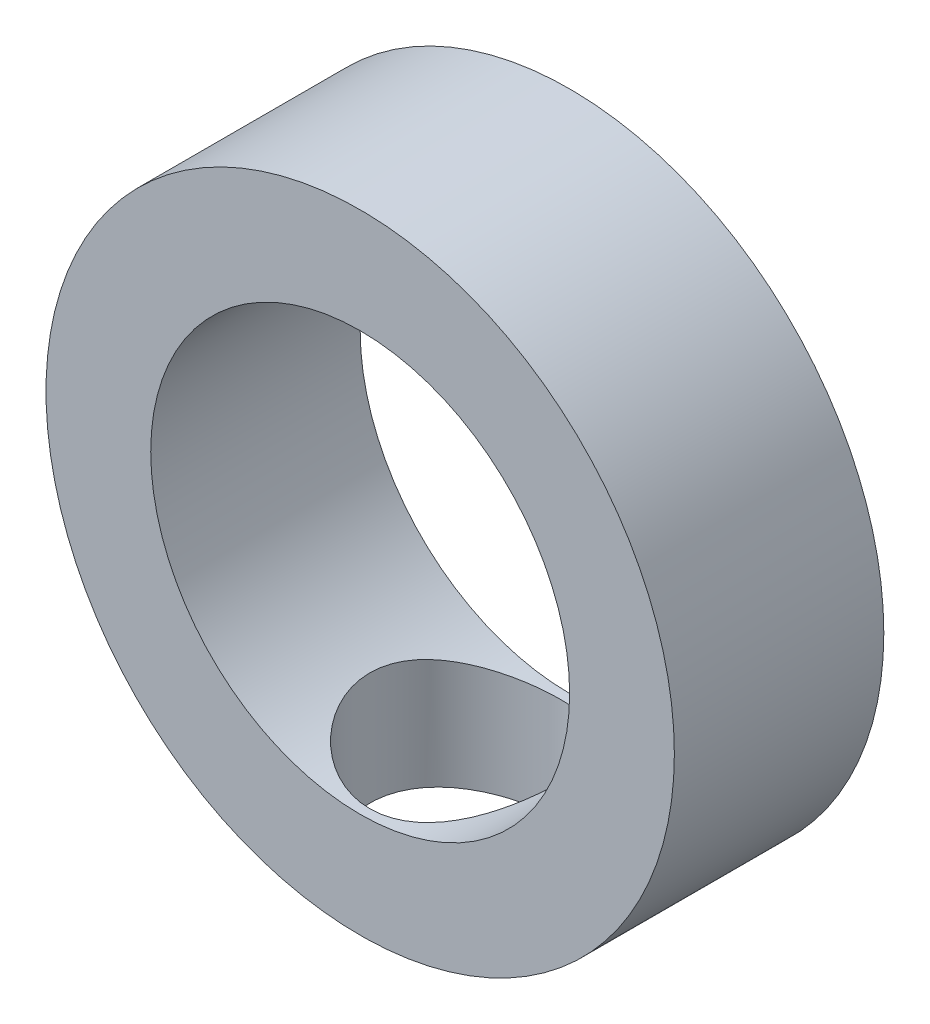
from build123d import *

# Parameters (mm, degrees)
SKETCH1_R           = 7.5
SKETCH1_R_2         = 5
BOSS_EXTRUDE1_DEPTH = 2.5
SKETCH4_R           = 2.268112058
CUT_EXTRUDE1_DEPTH  = 10


with BuildPart() as part:
    # Sketch1 → Boss-Extrude1 (new body, symmetric)
    with BuildSketch(Plane.XY):
        Circle(SKETCH1_R)
        Circle(SKETCH1_R_2, mode=Mode.SUBTRACT)
    extrude(amount=BOSS_EXTRUDE1_DEPTH, both=True)

    # Sketch4 → Cut-Extrude1 (cut)
    with BuildSketch(Plane(origin=(0, 0, 0), x_dir=(1, 0, 0), z_dir=(0, 1, 0))):
        Circle(SKETCH4_R)
    extrude(amount=-CUT_EXTRUDE1_DEPTH, mode=Mode.SUBTRACT)


solid = part.part
